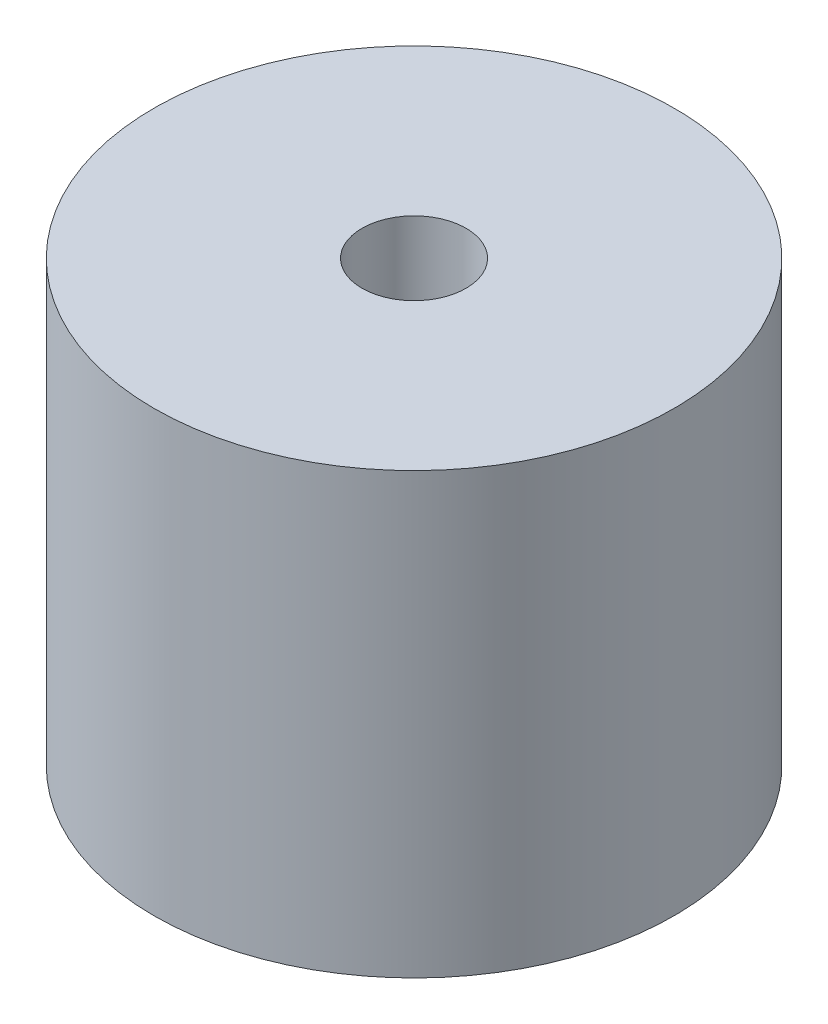
from build123d import *

# Parameters (mm, degrees)
SKETCH1_R           = 7.9375
SKETCH1_R_2         = 1.5875
BOSS_EXTRUDE1_DEPTH = 13.4112


with BuildPart() as part:
    # Sketch1 → Boss-Extrude1 (new body)
    with BuildSketch(Plane(origin=(0, 0, 0), x_dir=(1, 0, 0), z_dir=(0, 1, 0))):
        Circle(SKETCH1_R)
        Circle(SKETCH1_R_2, mode=Mode.SUBTRACT)
    extrude(amount=BOSS_EXTRUDE1_DEPTH)


solid = part.part
